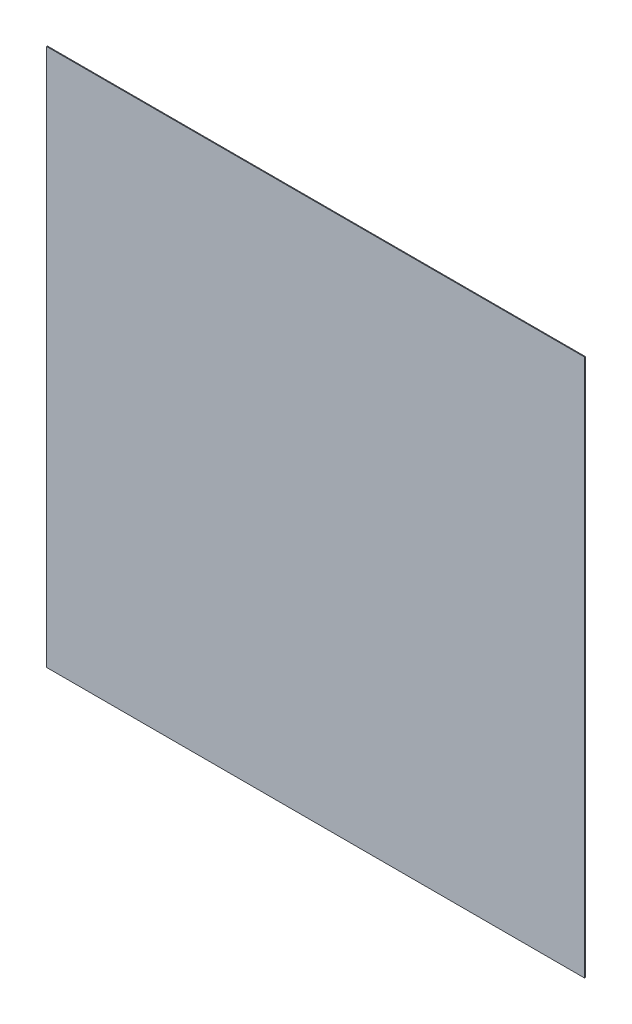
from build123d import *

# Parameters (mm, degrees)
SKETCH1_W           = 63.5
SKETCH1_H           = 63.5
BOSS_EXTRUDE1_DEPTH = 0.1


with BuildPart() as part:
    # Sketch1 → Boss-Extrude1 (new body)
    with BuildSketch(Plane.XY):
        Rectangle(SKETCH1_W, SKETCH1_H)
    extrude(amount=BOSS_EXTRUDE1_DEPTH)


solid = part.part
